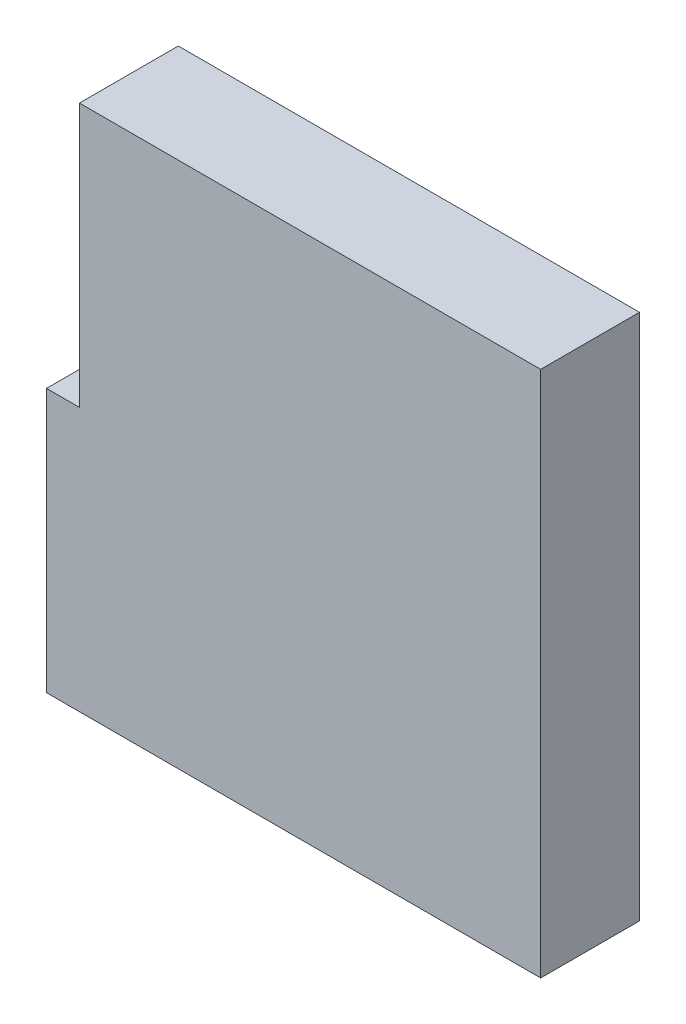
from build123d import *

# Parameters (mm, degrees)
BOSS_EXTRUDE1_DEPTH = 38.1


with BuildPart() as part:
    # Sketch1 → Boss-Extrude1 (new body)
    with BuildSketch(Plane.XY):
        Polygon((-190.5, 101.6), (-190.5, 0), (0, 0), (0, 203.2), (-177.8, 203.2), (-177.8, 101.6), align=None)
    extrude(amount=BOSS_EXTRUDE1_DEPTH)


solid = part.part
